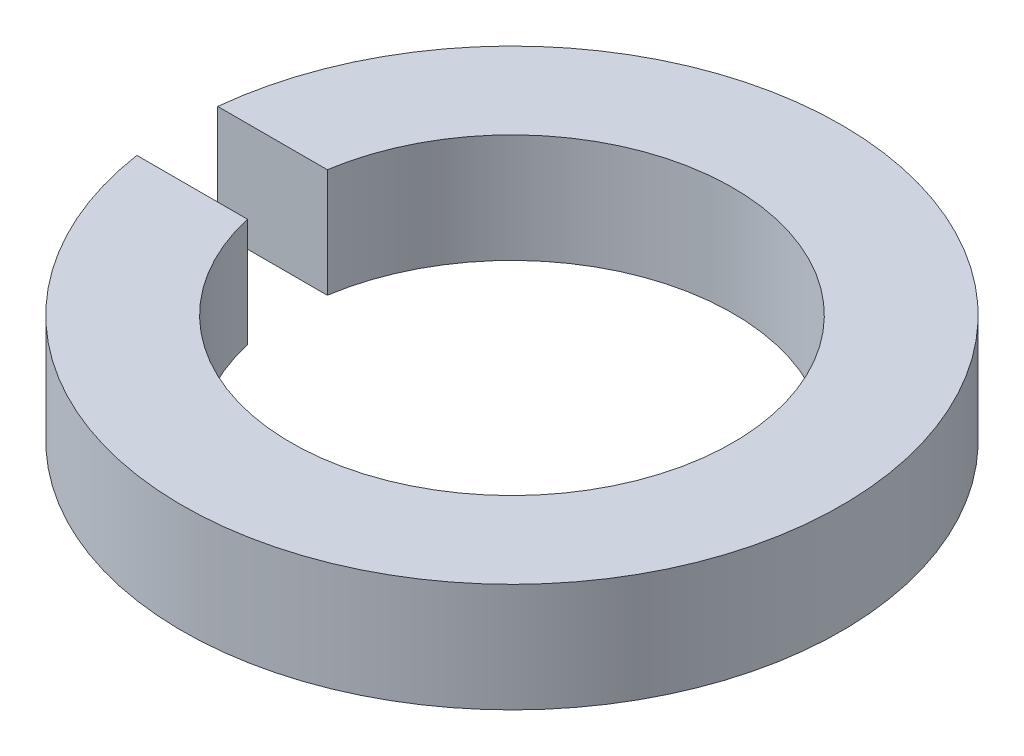
from build123d import *

# Parameters (mm, degrees)
EXTRUDE_1_DEPTH = 0.8


with BuildPart() as part:
    # 草图1 → 凸台-拉伸1 (new body)
    with BuildSketch(Plane(origin=(0, 0, 0), x_dir=(1, 0, 0), z_dir=(0, 1, 0))):
        with BuildLine():
            Line((-1.605994786, 0.247801833), (-2.412305796, 0.247801833))
            ThreePointArc((-2.412305796, 0.247801833), (2.424324915, 0.057216323), (-2.397929768, -0.361327866))
            Line((-2.397929768, -0.361327866), (-1.584319151, -0.361327866))
            ThreePointArc((-1.584319151, -0.361327866), (1.623972137, 0.057788393), (-1.605994786, 0.247801833))
        make_face()
    extrude(amount=EXTRUDE_1_DEPTH)


solid = part.part
